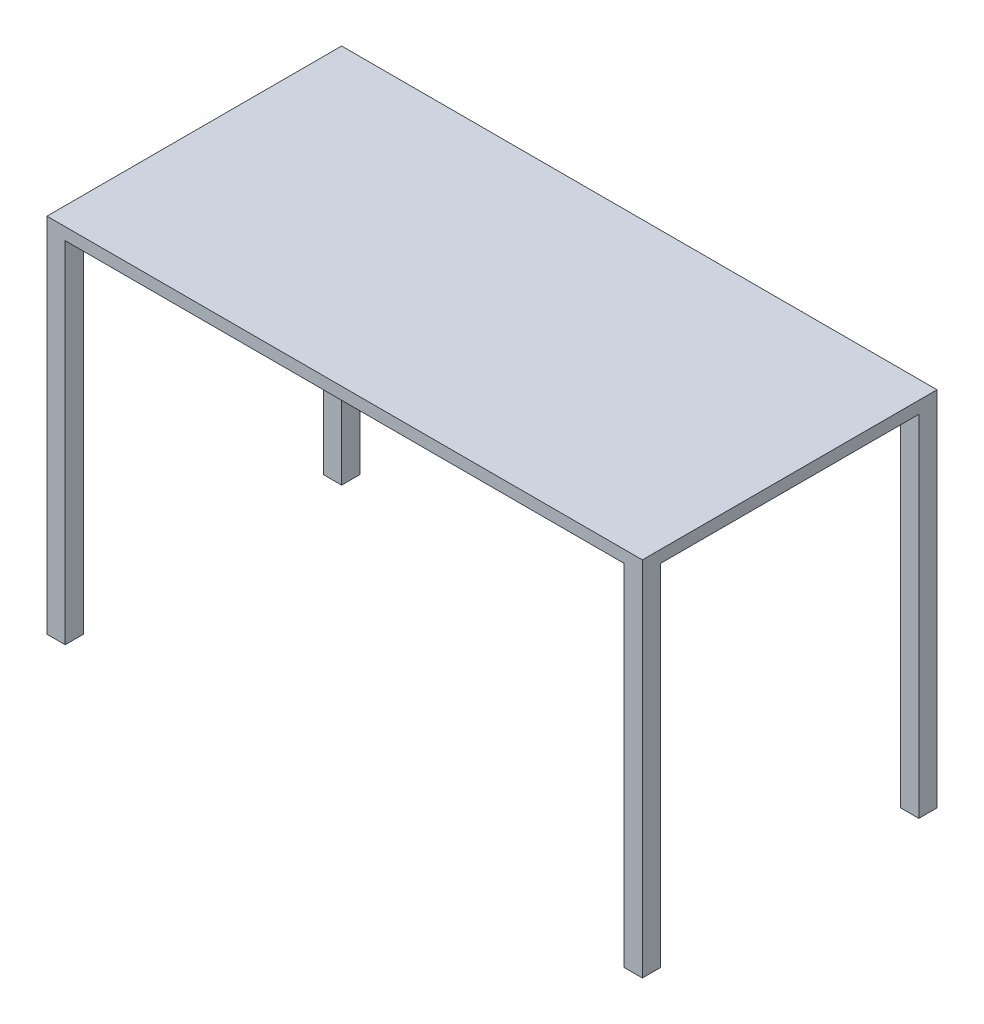
from build123d import *

# Parameters (mm, degrees)
SKETCH1_W           = 1244.6
SKETCH1_H           = 615.95
BOSS_EXTRUDE1_DEPTH = 25.4
SKETCH3_W           = 38.1
SKETCH3_H           = 38.1
BOSS_EXTRUDE2_DEPTH = 731.52


with BuildPart() as part:
    # Sketch1 → Boss-Extrude1 (new body)
    with BuildSketch(Plane(origin=(0, 0, 0), x_dir=(1, 0, 0), z_dir=(0, 1, 0))):
        Rectangle(SKETCH1_W, SKETCH1_H)
    extrude(amount=BOSS_EXTRUDE1_DEPTH)

    # Sketch3 → Boss-Extrude2 (add)
    with BuildSketch(Plane.XZ):
        with Locations((-603.25, 288.925)):
            Rectangle(SKETCH3_W, SKETCH3_H)
        with Locations((603.25, 288.925)):
            Rectangle(SKETCH3_W, SKETCH3_H)
        with Locations((603.25, -288.925)):
            Rectangle(SKETCH3_W, SKETCH3_H)
        with Locations((-603.25, -288.925)):
            Rectangle(SKETCH3_W, SKETCH3_H)
    extrude(amount=BOSS_EXTRUDE2_DEPTH)


solid = part.part
